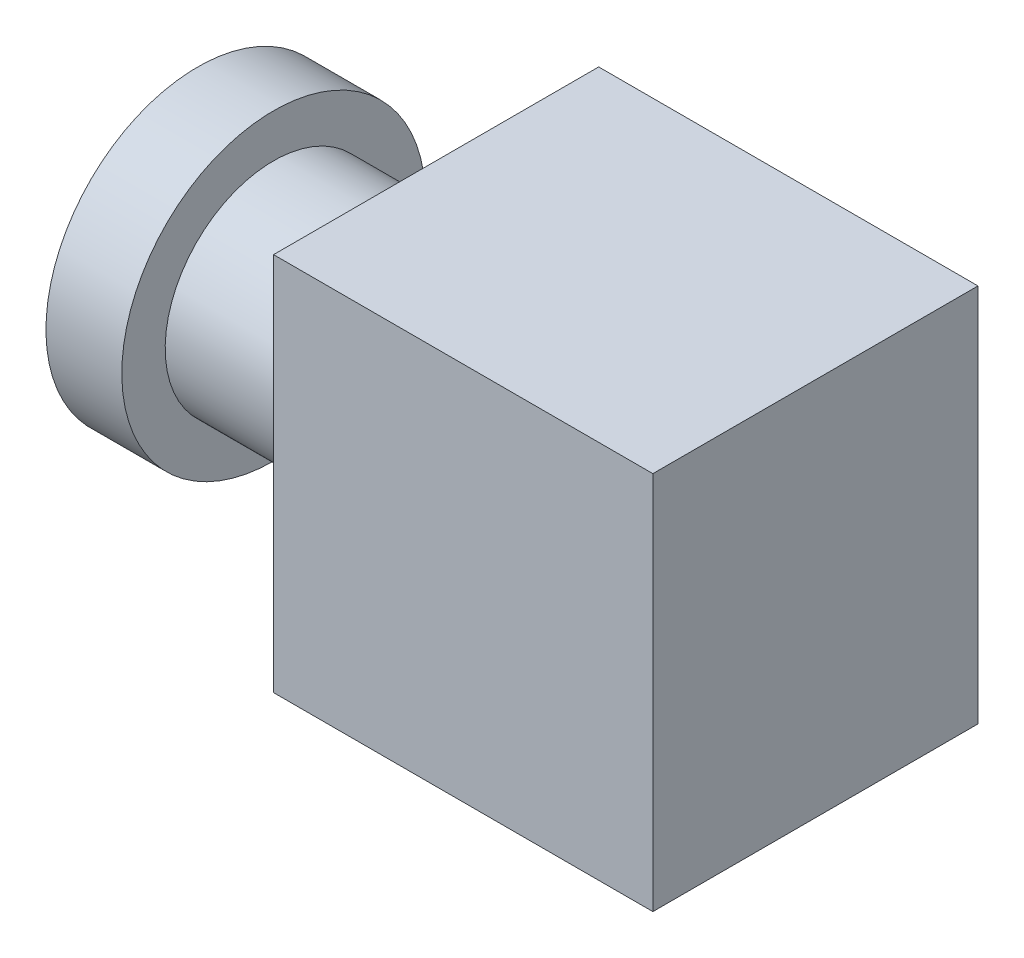
from build123d import *

# Parameters (mm, degrees)
SKETCH1_W           = 35
SKETCH1_H           = 35
BOSS_EXTRUDE1_DEPTH = 30
SKETCH2_R           = 10
BOSS_EXTRUDE2_DEPTH = 15
SKETCH3_R           = 14
BOSS_EXTRUDE3_DEPTH = 7


with BuildPart() as part:
    # Sketch1 → Boss-Extrude1 (new body)
    with BuildSketch(Plane.XY):
        Rectangle(SKETCH1_W, SKETCH1_H)
    extrude(amount=BOSS_EXTRUDE1_DEPTH)

    # Sketch2 → Boss-Extrude2 (add)
    with BuildSketch(Plane.ZY.offset(17.5)):
        with Locations((15, 0)):
            Circle(SKETCH2_R)
    extrude(amount=BOSS_EXTRUDE2_DEPTH)

    # Sketch3 → Boss-Extrude3 (add)
    with BuildSketch(Plane.ZY.offset(32.5)):
        with Locations((15, 0)):
            Circle(SKETCH3_R)
    extrude(amount=BOSS_EXTRUDE3_DEPTH)


solid = part.part
